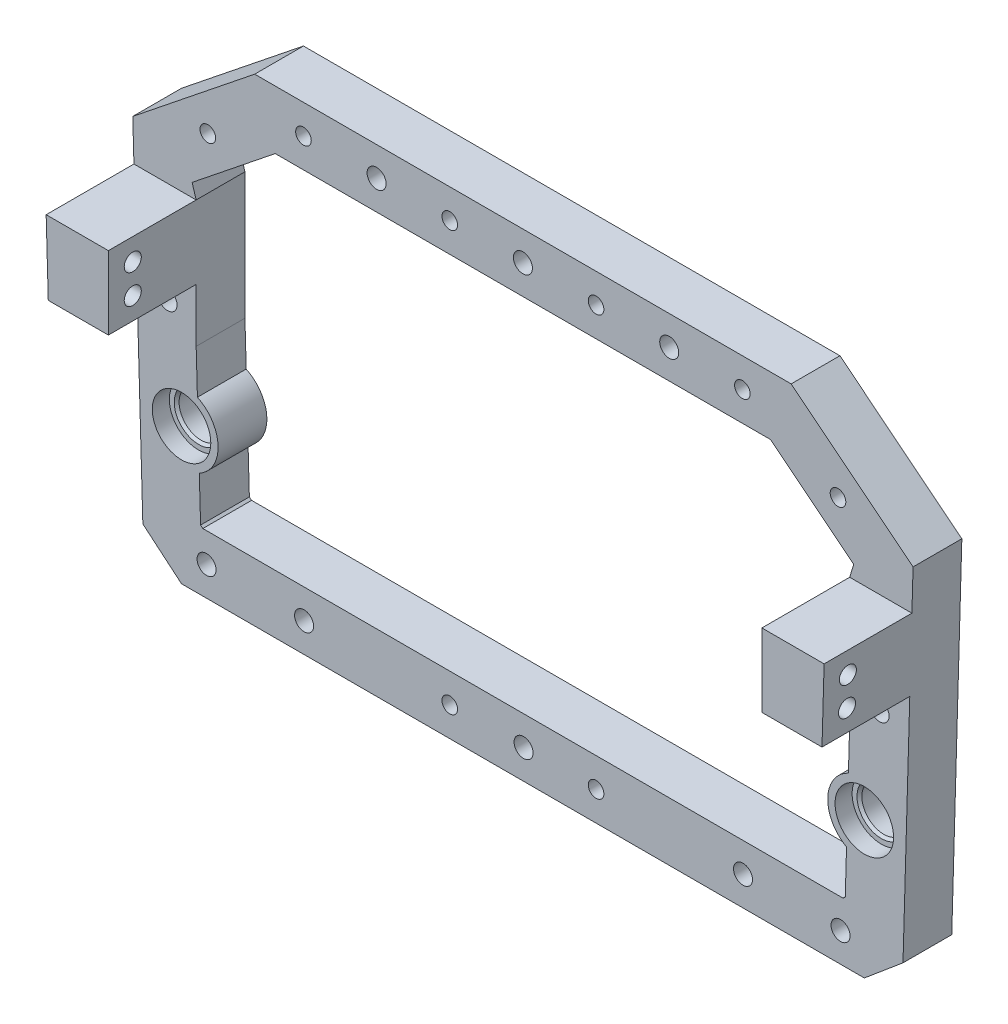
from build123d import *

# Parameters (mm, degrees)
SKETCH1_R               = 6
SKETCH1_R_2             = 1.6
BOSS_EXTRUDE1_DEPTH     = 10
BOSS_EXTRUDE2_DEPTH     = 18
SKETCH7_R               = 1.75
CUT_EXTRUDE4_DEPTH      = 148
CUT_EXTRUDE4_DEPTH_BACK = 14
SKETCH8_R               = 2.65
CUT_EXTRUDE5_DEPTH      = 3.5
BOSS_EXTRUDE3_START     = -10
SKETCH10_R              = 6.870136932
SKETCH10_R_2            = 4.5
SKETCH10_R_3            = 6.9172188
BOSS_EXTRUDE3_DEPTH     = 6.5
SKETCH11_R              = 1.95
CUT_EXTRUDE6_DEPTH      = 29
CHAMFER1_SIZE           = 0.5


with BuildPart() as part:
    # Sketch1 → Boss-Extrude1 (new body)
    with BuildSketch(Plane.XY):
        Polygon((-55.131687722, 48.97503592), (54.868312278, 48.97503592), (79.868312278, 28.97503592), (77.800969503, -42.368674328), (69.868312278, -49.02496408), (-70.131687722, -49.02496408), (-78.064344947, -42.368674328), (-80.131687722, 28.97503592), align=None)
        with Locations((-70.131687722, -21.02496408)):
            Circle(SKETCH1_R, mode=Mode.SUBTRACT)
        with Locations((69.868312278, -21.02496408)):
            Circle(SKETCH1_R, mode=Mode.SUBTRACT)
        with Locations((-45.131687722, 42.97503592)):
            Circle(SKETCH1_R_2, mode=Mode.SUBTRACT)
        with Locations((-15.131687722, 42.97503592)):
            Circle(SKETCH1_R_2, mode=Mode.SUBTRACT)
        with Locations((14.868312278, 42.97503592)):
            Circle(SKETCH1_R_2, mode=Mode.SUBTRACT)
        with Locations((44.868312278, 42.97503592)):
            Circle(SKETCH1_R_2, mode=Mode.SUBTRACT)
        with Locations((-64.740033508, 33.604610207)):
            Circle(SKETCH1_R_2, mode=Mode.SUBTRACT)
        with Locations((64.476658063, 33.604610207)):
            Circle(SKETCH1_R_2, mode=Mode.SUBTRACT)
        with Locations((-15.131687722, -43.02496408)):
            Circle(SKETCH1_R_2, mode=Mode.SUBTRACT)
        with Locations((14.868312278, -43.02496408)):
            Circle(SKETCH1_R_2, mode=Mode.SUBTRACT)
        with BuildLine():
            Line((-67.963425231, 23.342147743), (-50.92231501, 36.97503592))
            Line((-50.92231501, 36.97503592), (50.658939565, 36.97503592))
            Line((50.658939565, 36.97503592), (67.700049787, 23.342147743))
            Line((67.700049787, 23.342147743), (66.868312278, 20.639002542))
            Line((66.868312278, 20.639002542), (66.868312278, -5.360997458))
            Line((66.868312278, -5.360997458), (66.610164686, -14.269634756))
            ThreePointArc((66.610164686, -14.269634756), (62.371459095, -20.807726075), (66.224458755, -27.580292561))
            Line((66.224458755, -27.580292561), (65.961995417, -36.637865644))
            Line((65.961995417, -36.637865644), (65.500669466, -37.02496408))
            Line((65.500669466, -37.02496408), (-65.764044911, -37.02496408))
            Line((-65.764044911, -37.02496408), (-66.225370862, -36.637865644))
            Line((-66.225370862, -36.637865644), (-66.487834199, -27.580292561))
            ThreePointArc((-66.487834199, -27.580292561), (-62.634834539, -20.807726075), (-66.873540131, -14.269634756))
            Line((-66.873540131, -14.269634756), (-67.131687722, -5.360997458))
            Line((-67.131687722, -5.360997458), (-67.131687722, 20.639002542))
            Line((-67.131687722, 20.639002542), (-67.963425231, 23.342147743))
        make_face(mode=Mode.SUBTRACT)
    extrude(amount=BOSS_EXTRUDE1_DEPTH)

    # Sketch5 → Boss-Extrude2 (add)
    with BuildSketch(Plane.XY.offset(10)):
        Polygon((66.868312278, 20.639002542), (79.192098778, 20.639002542), (79.626757159, 20.639002542), (79.192098778, 5.639002542), (66.868312278, 5.639002542), align=None)
        Polygon((-79.890132604, 20.639002542), (-79.455474222, 5.639002542), (-67.131687722, 5.639002542), (-67.131687722, 20.639002542), (-79.455474222, 20.639002542), align=None)
    extrude(amount=BOSS_EXTRUDE2_DEPTH)

    # Sketch7 → Cut-Extrude4 (cut, two sides)
    with BuildSketch(Plane(origin=(-67.131687722, 0, 0), x_dir=(0, 0, -1), z_dir=(1, 0, 0))) as cut_extrude4_sk:
        with Locations((-23, 16.139002542)):
            Circle(SKETCH7_R)
        with Locations((-23, 10.139002542)):
            Circle(SKETCH7_R)
    extrude(amount=CUT_EXTRUDE4_DEPTH, mode=Mode.SUBTRACT)
    extrude(cut_extrude4_sk.sketch, amount=-CUT_EXTRUDE4_DEPTH_BACK, mode=Mode.SUBTRACT)

    # Sketch8 → Cut-Extrude5 (cut)
    with BuildSketch(Plane(origin=(0, 0, 0), x_dir=(-1, 0, 0), z_dir=(0, 0, -1))):
        with Locations((-14.868312278, 42.97503592)):
            Circle(SKETCH8_R)
        with Locations((15.131687722, 42.97503592)):
            Circle(SKETCH8_R)
        with Locations((45.131687722, 42.97503592)):
            Circle(SKETCH8_R)
        with Locations((64.740033508, 33.604610207)):
            Circle(SKETCH8_R)
        with Locations((-64.476658063, 33.604610207)):
            Circle(SKETCH8_R)
        with Locations((-44.868312278, 42.97503592)):
            Circle(SKETCH8_R)
        with Locations((-14.868312278, -43.02496408)):
            Circle(SKETCH8_R)
        with Locations((15.131687722, -43.02496408)):
            Circle(SKETCH8_R)
    extrude(amount=-CUT_EXTRUDE5_DEPTH, mode=Mode.SUBTRACT)

    # Sketch10 → Boss-Extrude3 (add)
    with BuildSketch(Plane.XY.offset(10).offset(BOSS_EXTRUDE3_START)):
        with Locations((-70.131687722, -21.02496408)):
            Circle(SKETCH10_R)
        with Locations((-70.131687722, -21.02496408)):
            Circle(SKETCH10_R_2, mode=Mode.SUBTRACT)
        with Locations((69.868312278, -21.02496408)):
            Circle(SKETCH10_R_3)
        with Locations((69.868312278, -21.02496408)):
            Circle(SKETCH10_R_2, mode=Mode.SUBTRACT)
    extrude(amount=BOSS_EXTRUDE3_DEPTH)

    # Sketch11 → Cut-Extrude6 (cut, through all)
    with BuildSketch(Plane(origin=(0, 0, 0), x_dir=(-1, 0, 0), z_dir=(0, 0, -1))):
        with Locations((-29.868312278, 42.97503592)):
            Circle(SKETCH11_R)
        with Locations((0.131687722, 42.97503592)):
            Circle(SKETCH11_R)
        with Locations((30.131687722, 42.97503592)):
            Circle(SKETCH11_R)
        with Locations((0, -43.02496408)):
            Circle(SKETCH11_R)
        with Locations((-45, -43.02496408)):
            Circle(SKETCH11_R)
        with Locations((45, -43.02496408)):
            Circle(SKETCH11_R)
        with Locations((-65, -43.02496408)):
            Circle(SKETCH11_R)
        with Locations((65, -43.02496408)):
            Circle(SKETCH11_R)
        with Locations((-73, 0)):
            Circle(SKETCH11_R)
        with Locations((73, 0)):
            Circle(SKETCH11_R)
    extrude(amount=-CUT_EXTRUDE6_DEPTH, mode=Mode.SUBTRACT)

    # Chamfer1
    chamfer1_edges = [part.edges().sort_by_distance(p)[0] for p in [
        (65.368312278, -21.02496408, 6.5),
        (-74.631687722, -21.02496408, 6.5),
    ]]
    chamfer(chamfer1_edges, length=CHAMFER1_SIZE)


solid = part.part
